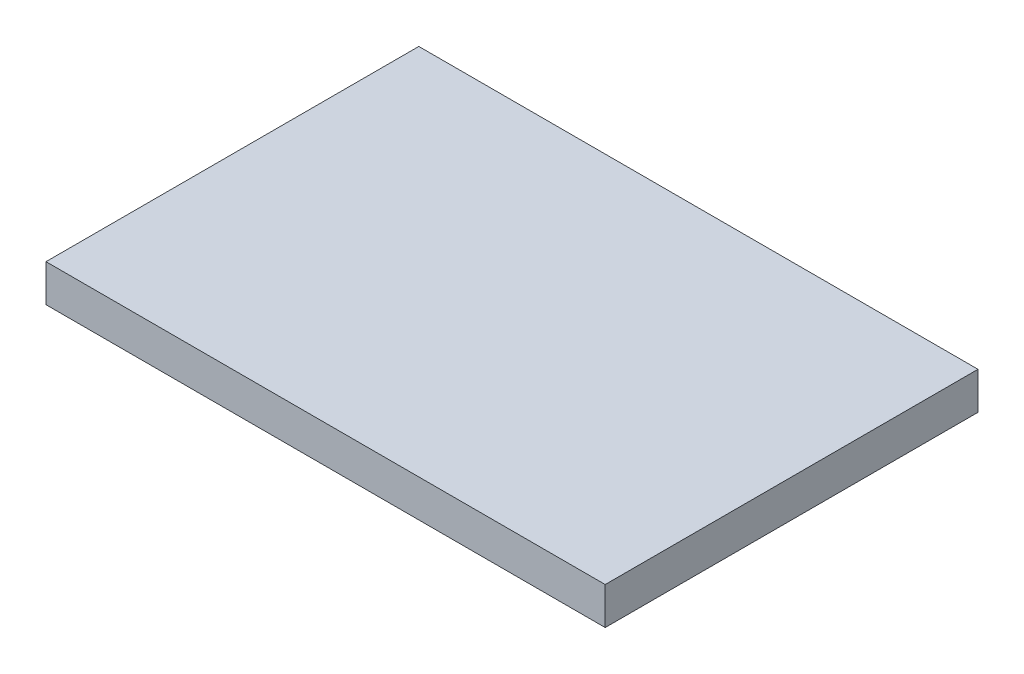
from build123d import *

# Parameters (mm, degrees)
ESQUISSE1_W        = 150
ESQUISSE1_H        = 100
BOSS_EXTRU_1_DEPTH = 10


with BuildPart() as part:
    # Esquisse1 → Boss.-Extru.1 (new body)
    with BuildSketch(Plane(origin=(0, 0, 0), x_dir=(1, 0, 0), z_dir=(0, 1, 0))):
        with Locations((75, 50)):
            Rectangle(ESQUISSE1_W, ESQUISSE1_H)
    extrude(amount=BOSS_EXTRU_1_DEPTH)


solid = part.part
